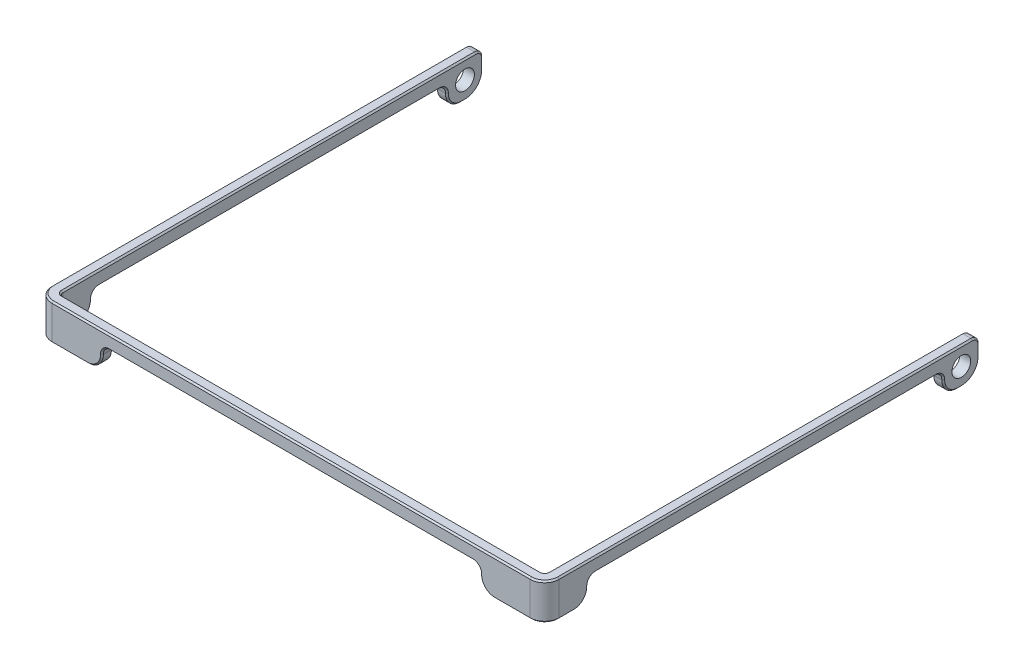
from build123d import *

# Parameters (mm, degrees)
EXTRUDE_1_DEPTH     = 5
FILLET_1_R          = 2
FILLET_2_R          = 0.5
FILLET_3_R          = 2.5
SKETCH_2_R          = 1.3
CUT_EXTRUDE_1_DEPTH = 100
SKETCH_3_W          = 52.2
SKETCH_3_H          = 6.2
CUT_EXTRUDE_2_DEPTH = 5
FILLET_5_R          = 1
SKETCH_4_W          = 49
SKETCH_4_H          = 8.82072143
CUT_EXTRUDE_3_DEPTH = 100
FILLET_6_R          = 1
FILLET_7_R          = 2
CHAMFER_1_SIZE      = 0.2


with BuildPart() as part:
    # 草图1 → 凸台-拉伸1 (new body)
    with BuildSketch(Plane(origin=(0, 0, 0), x_dir=(1, 0, 0), z_dir=(0, 1, 0))):
        Polygon((33.5, 29.25), (35, 29.25), (35, -30.75), (-35, -30.75), (-35, 29.25), (-33.5, 29.25), (-33.5, -29.25), (33.5, -29.25), align=None)
    extrude(amount=EXTRUDE_1_DEPTH)

    # 圆角1
    fillet_1_edges = [part.edges().sort_by_distance(p)[0] for p in [
        (35, 2.5, 30.75),
        (-35, 2.5, 30.75),
    ]]
    fillet(fillet_1_edges, radius=FILLET_1_R)

    # 圆角2
    fillet_2_edges = [part.edges().sort_by_distance(p)[0] for p in [
        (-33.5, 2.5, 29.25),
        (33.5, 2.5, 29.25),
    ]]
    fillet(fillet_2_edges, radius=FILLET_2_R)

    # 圆角3
    fillet_3_edges = [part.edges().sort_by_distance(p)[0] for p in [
        (-34.25, 0, -29.25),
        (34.25, 0, -29.25),
    ]]
    fillet(fillet_3_edges, radius=FILLET_3_R)

    # 草图2 → 切除-拉伸1 (cut)
    with BuildSketch(Plane.ZY.offset(35)):
        with Locations((-26.75, 2.5)):
            Circle(SKETCH_2_R)
    extrude(amount=-CUT_EXTRUDE_1_DEPTH, mode=Mode.SUBTRACT)

    # 草图3 → 切除-拉伸2 (cut)
    with BuildSketch(Plane.XY.offset(30.75)):
        Rectangle(SKETCH_3_W, SKETCH_3_H)
    extrude(amount=-CUT_EXTRUDE_2_DEPTH, mode=Mode.SUBTRACT)

    # 圆角5
    fillet_5_edges = [part.edges().sort_by_distance(p)[0] for p in [
        (-26.1, 3.1, 30),
        (26.1, 3.1, 30),
    ]]
    fillet(fillet_5_edges, radius=FILLET_5_R)

    # 草图4 → 切除-拉伸3 (cut)
    with BuildSketch(Plane.ZY.offset(35)):
        with Locations((0.25, -1.310360715)):
            Rectangle(SKETCH_4_W, SKETCH_4_H)
    extrude(amount=-CUT_EXTRUDE_3_DEPTH, mode=Mode.SUBTRACT)

    # 圆角6
    fillet_6_edges = [part.edges().sort_by_distance(p)[0] for p in [
        (34.25, 3.1, -24.25),
        (-34.25, 3.1, -24.25),
        (34.25, 3.1, 24.75),
        (-34.25, 3.1, 24.75),
        (-34.25, 5, -29.25),
        (34.25, 5, -29.25),
    ]]
    fillet(fillet_6_edges, radius=FILLET_6_R)

    # 圆角7
    fillet_7_edges = [part.edges().sort_by_distance(p)[0] for p in [
        (-34.25, 0, 24.75),
        (-34.25, 0, -24.25),
        (34.25, 0, -24.25),
        (34.25, 0, 24.75),
        (-26.1, 0, 30),
        (26.1, 0, 30),
    ]]
    fillet(fillet_7_edges, radius=FILLET_7_R)

    # 倒角1
    chamfer_1_edges = [part.edges().sort_by_distance(p)[0] for p in [
        (33.5, 5, 0.25),
        (-35, 5, 0.25),
        (-35, 2.05, -24.25),
        (-35, 3.1, 0.25),
        (-35, 3.25, -29.25),
        (-35, 4.707106781, -28.957106781),
        (-33.5, 3.25, -29.25),
        (-33.5, 3.1, 0.25),
        (-33.5, 2.05, -24.25),
        (-33.5, 4.707106781, -28.957106781),
        (33.5, 3.1, 0.25),
        (33.5, 2.05, 24.75),
        (33.5, 3.25, -29.25),
        (33.5, 4.707106781, -28.957106781),
        (35, 3.25, -29.25),
        (35, 3.1, 0.25),
        (35, 2.05, -24.25),
        (35, 4.707106781, -28.957106781),
        (33.5, 2.807106781, -23.957106781),
        (35, 2.807106781, -23.957106781),
        (33.5, 2.807106781, 24.457106781),
        (35, 2.807106781, 24.457106781),
        (-35, 2.807106781, 24.457106781),
        (-33.5, 2.807106781, 24.457106781),
        (-35, 2.807106781, -23.957106781),
        (-33.5, 2.807106781, -23.957106781),
        (35, 0, -26.5),
        (33.5, 2.05, -24.25),
        (33.5, 0, 27.75),
        (33.5, 0.585786438, 25.335786438),
        (33.5, 0.585786438, -24.835786438),
        (35, 2.05, 24.75),
        (35, 0.585786438, 25.335786438),
        (35, 0.585786438, -24.835786438),
        (-33.5, 0, -26.5),
        (-35, 2.05, 24.75),
        (-35, 0, 27.75),
        (-35, 0.585786438, 25.335786438),
        (-35, 0.585786438, -24.835786438),
        (-33.5, 2.05, 24.75),
        (-33.5, 0.585786438, 25.335786438),
        (-33.5, 0.585786438, -24.835786438),
        (-30.55, 0, 29.25),
        (26.1, 2.05, 30.75),
        (30.55, 0, 30.75),
        (26.685786438, 0.585786438, 30.75),
        (-26.685786438, 0.585786438, 30.75),
        (26.1, 2.05, 29.25),
        (26.685786438, 0.585786438, 29.25),
        (-26.685786438, 0.585786438, 29.25),
        (35, 0, 27.75),
        (35, 5, 0.25),
        (-30.55, 0, 30.75),
        (-34.414213562, 0, 30.164213562),
        (34.414213562, 0, 30.164213562),
        (0, 5, 30.75),
        (-34.414213562, 5, 30.164213562),
        (34.414213562, 5, 30.164213562),
        (30.55, 0, 29.25),
        (0, 5, 29.25),
        (-33.5, 0, 27.75),
        (-33.5, 5, 0.25),
        (33.353553391, 0, 29.103553391),
        (33.353553391, 5, 29.103553391),
        (-33.353553391, 0, 29.103553391),
        (-33.353553391, 5, 29.103553391),
        (33.5, 0, -26.5),
        (33.5, 0.732233047, -28.517766953),
        (-35, 0, -26.5),
        (35, 0.732233047, -28.517766953),
        (-35, 0.732233047, -28.517766953),
        (-33.5, 0.732233047, -28.517766953),
        (0, 3.1, 30.75),
        (0, 3.1, 29.25),
        (-26.1, 2.05, 30.75),
        (-26.1, 2.05, 29.25),
        (25.807106781, 2.807106781, 30.75),
        (25.807106781, 2.807106781, 29.25),
        (-25.807106781, 2.807106781, 30.75),
        (-25.807106781, 2.807106781, 29.25),
    ]]
    chamfer(chamfer_1_edges, length=CHAMFER_1_SIZE)


solid = part.part
